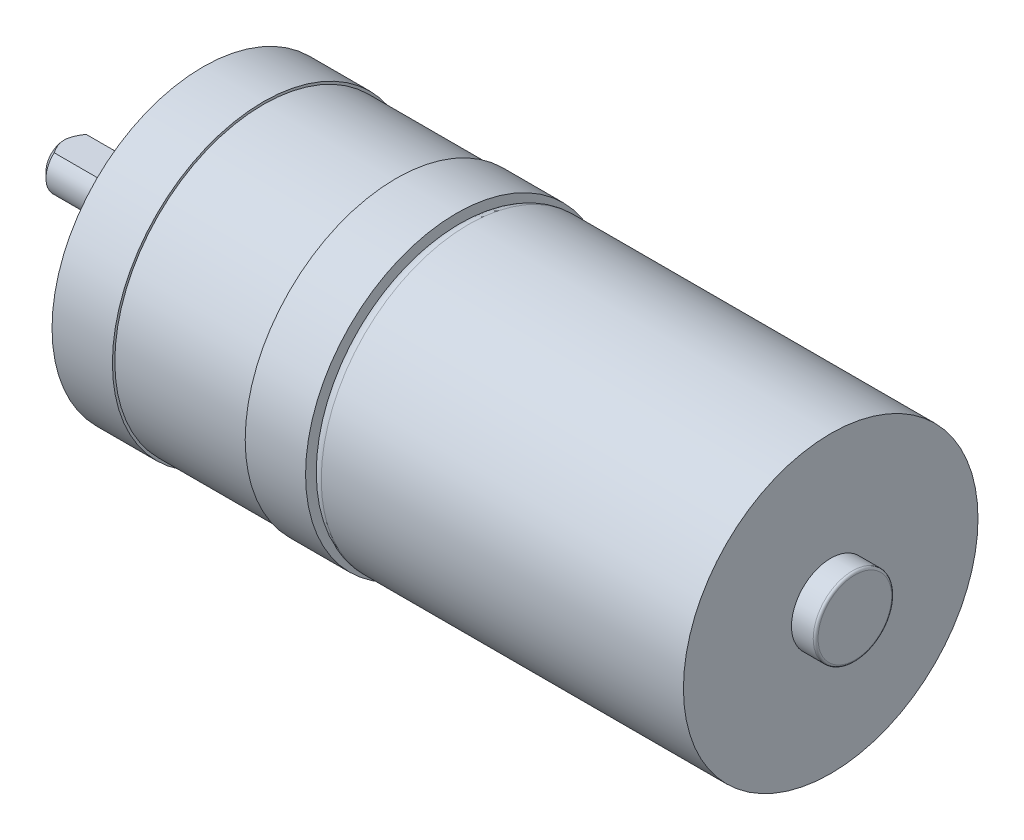
from build123d import *

# Parameters (mm, degrees)
CUT_EXTRUDE1_DEPTH = 8


with BuildPart() as part:
    # Sketch1 → Revolve1 (revolve)
    with BuildSketch(Plane.XY):
        with BuildLine():
            Line((-9.946660926, -3.531651516), (-9.946660926, -12.5))
            Line((-9.946660926, -12.5), (-4.946660926, -12.5))
            Line((-4.946660926, -12.5), (-4.946660926, -12.3))
            Line((-4.946660926, -12.3), (6.053339074, -12.3))
            Line((6.053339074, -12.3), (6.053339074, -12.5))
            Line((6.053339074, -12.5), (11.053339074, -12.5))
            Line((11.053339074, -12.5), (11.053339074, -11.2))
            ThreePointArc((11.053339074, -11.2), (11.346232293, -11.907106781), (12.053339074, -12.2))
            Line((12.053339074, -12.2), (42.053339074, -12.2))
            Line((42.053339074, -12.2), (42.053339074, -3.25))
            Line((42.053339074, -3.25), (43.853339074, -3.25))
            ThreePointArc((43.853339074, -3.25), (43.99476043, -3.191421356), (44.053339074, -3.05))
            Line((44.053339074, -3.05), (44.053339074, 0))
            Line((44.053339074, 0), (-21.446660926, 0))
            Line((-21.446660926, 0), (-21.446660926, -1.5))
            Line((-21.446660926, -1.5), (-20.946660926, -2))
            Line((-20.946660926, -2), (-12.446660926, -2))
            Line((-12.446660926, -2), (-12.446660926, -3.531651516))
            Line((-12.446660926, -3.531651516), (-9.946660926, -3.531651516))
        make_face()
    revolve(axis=Axis((-21.446660926, 0, 0), (1, 0, 0)))

    # Sketch2 → Cut-Extrude1 (cut)
    with BuildSketch(Plane.ZY.offset(21.446660926)):
        with BuildLine():
            Line((-1.322875656, 1.5), (1.322875656, 1.5))
            ThreePointArc((1.322875656, 1.5), (0, 2), (-1.322875656, 1.5))
        make_face()
    extrude(amount=-CUT_EXTRUDE1_DEPTH, mode=Mode.SUBTRACT)


solid = part.part
